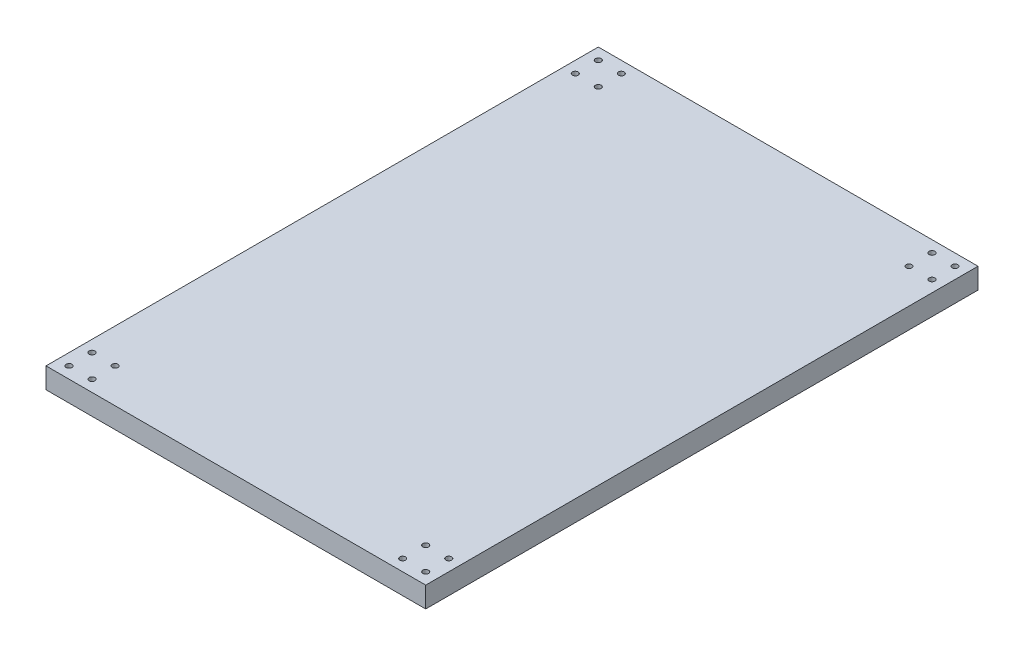
from build123d import *

# Parameters (mm, degrees)
SKETCH1_W           = 330
SKETCH1_H           = 480
SKETCH1_R           = 2.5
BOSS_EXTRUDE1_DEPTH = 18


with BuildPart() as part:
    # Sketch1 → Boss-Extrude1 (new body)
    with BuildSketch(Plane(origin=(0, 0, 0), x_dir=(1, 0, 0), z_dir=(0, 1, 0))):
        with Locations((165, 240)):
            Rectangle(SKETCH1_W, SKETCH1_H)
        with Locations((10, 10)):
            Circle(SKETCH1_R, mode=Mode.SUBTRACT)
        with Locations((30, 10)):
            Circle(SKETCH1_R, mode=Mode.SUBTRACT)
        with Locations((10, 30)):
            Circle(SKETCH1_R, mode=Mode.SUBTRACT)
        with Locations((30, 30)):
            Circle(SKETCH1_R, mode=Mode.SUBTRACT)
        with Locations((320, 30)):
            Circle(SKETCH1_R, mode=Mode.SUBTRACT)
        with Locations((320, 10)):
            Circle(SKETCH1_R, mode=Mode.SUBTRACT)
        with Locations((300, 10)):
            Circle(SKETCH1_R, mode=Mode.SUBTRACT)
        with Locations((300, 30)):
            Circle(SKETCH1_R, mode=Mode.SUBTRACT)
        with Locations((300, 470)):
            Circle(SKETCH1_R, mode=Mode.SUBTRACT)
        with Locations((320, 470)):
            Circle(SKETCH1_R, mode=Mode.SUBTRACT)
        with Locations((320, 450)):
            Circle(SKETCH1_R, mode=Mode.SUBTRACT)
        with Locations((300, 450)):
            Circle(SKETCH1_R, mode=Mode.SUBTRACT)
        with Locations((30, 470)):
            Circle(SKETCH1_R, mode=Mode.SUBTRACT)
        with Locations((10, 470)):
            Circle(SKETCH1_R, mode=Mode.SUBTRACT)
        with Locations((10, 450)):
            Circle(SKETCH1_R, mode=Mode.SUBTRACT)
        with Locations((30, 450)):
            Circle(SKETCH1_R, mode=Mode.SUBTRACT)
    extrude(amount=BOSS_EXTRUDE1_DEPTH)


solid = part.part
